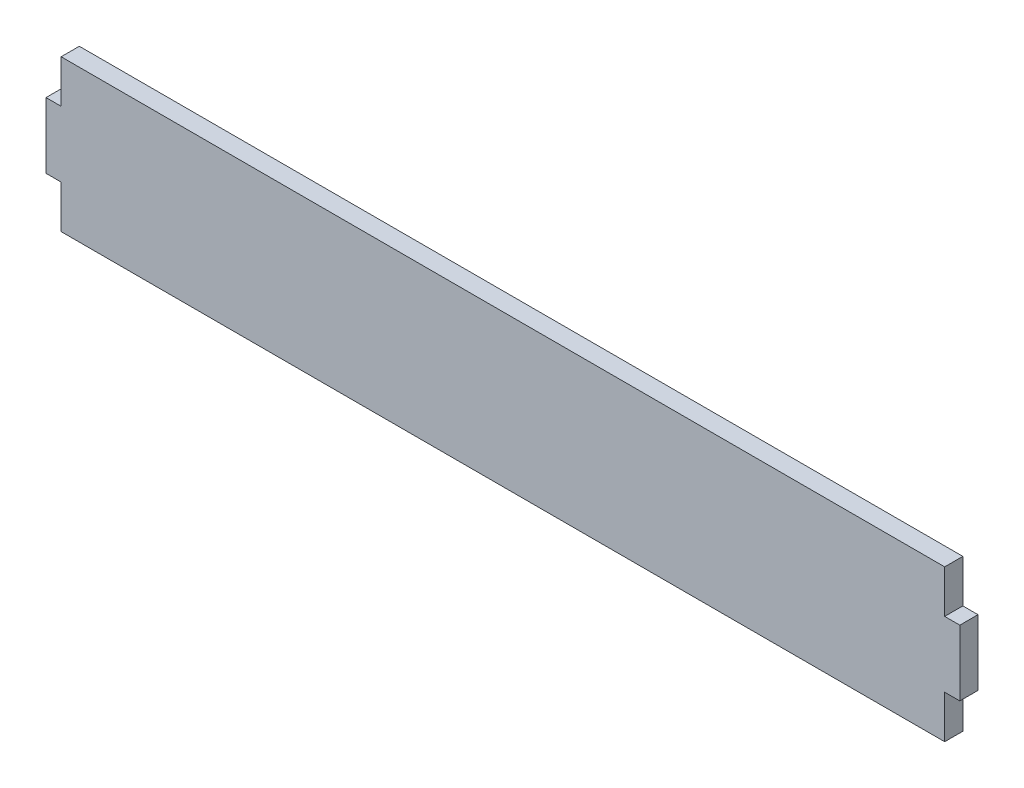
from build123d import *

# Parameters (mm, degrees)
BOSS_EXTRUDE1_DEPTH = 3.6


with BuildPart() as part:
    # Sketch1 → Boss-Extrude1 (new body)
    with BuildSketch(Plane.XY):
        Polygon((3, 21.5), (3, 30), (178, 30), (178, 21.5), (181, 21.5), (181, 8.5), (178, 8.5), (178, 0), (3, 0), (3, 8.5), (0, 8.5), (0, 21.5), align=None)
    extrude(amount=BOSS_EXTRUDE1_DEPTH)


solid = part.part
